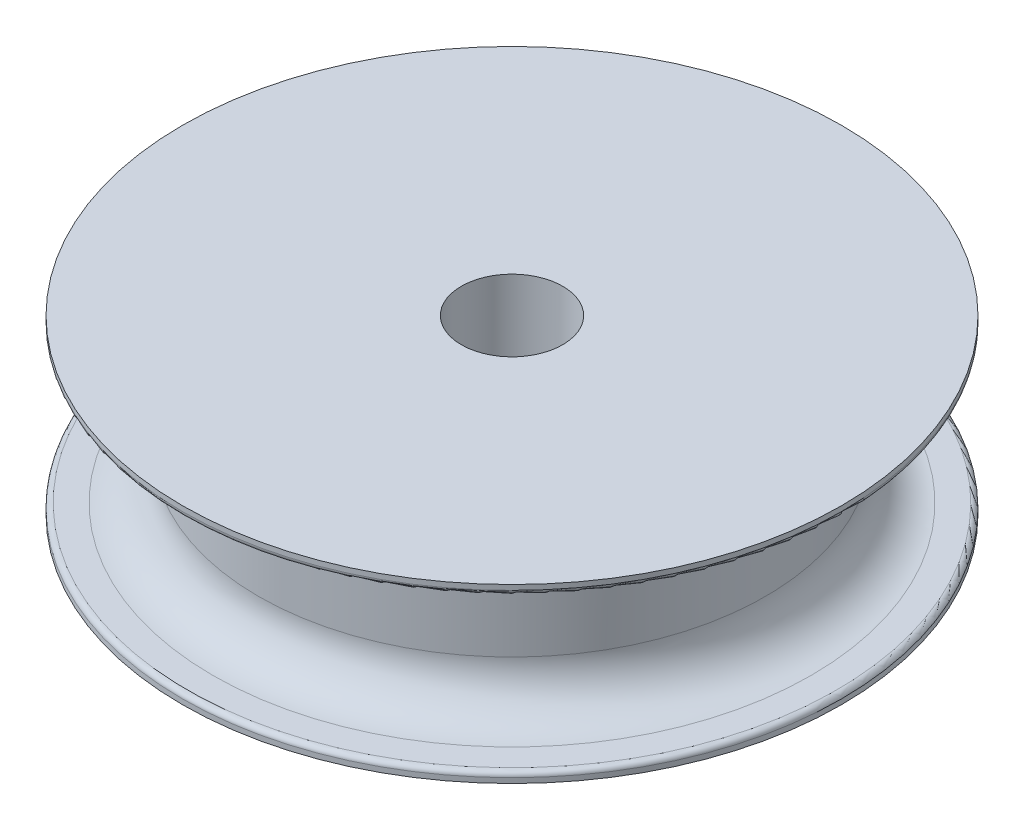
from build123d import *

# Parameters (mm, degrees)
BOSS_EXTRUDE1_DEPTH      = 15
BOSS_EXTRUDE1_DEPTH_BACK = 15
SKETCH1_R                = 50
SKETCH2_R                = 65
BOSS_EXTRUDE2_DEPTH      = 2
BOSS_EXTRUDE3_START      = 2
SKETCH3_R                = 65
BOSS_EXTRUDE3_DEPTH      = 2
FILLET1_R                = 9
FILLET2_R                = 1
FILLET3_R                = 1
FILLET4_R                = 9
CUT_EXTRUDE1_REACH       = 100.01
SKETCH4_R                = 10


with BuildPart() as part:
    # Sketch1 → Boss-Extrude1 (new, two sides: drawn at the far end of the back side and taken through both)
    with BuildSketch(Plane(origin=(0, 0, 0), x_dir=(1, 0, 0), z_dir=(0, 1, 0)).offset(-BOSS_EXTRUDE1_DEPTH_BACK)):
        Circle(SKETCH1_R)
    extrude(amount=BOSS_EXTRUDE1_DEPTH + BOSS_EXTRUDE1_DEPTH_BACK)

    # Sketch2 → Boss-Extrude2 (add)
    with BuildSketch(Plane.XZ.offset(15)):
        Circle(SKETCH2_R)
    extrude(amount=BOSS_EXTRUDE2_DEPTH)

    # Sketch3 → Boss-Extrude3 (add)
    with BuildSketch(Plane(origin=(0, 15, 0), x_dir=(1, 0, 0), z_dir=(0, 1, 0)).offset(BOSS_EXTRUDE3_START)):
        Circle(SKETCH3_R)
    extrude(amount=-BOSS_EXTRUDE3_DEPTH)

    # Fillet1
    fillet1_edges = [part.edges().sort_by_distance(p)[0] for p in [
        (-50, -15, 0),
    ]]
    fillet(fillet1_edges, radius=FILLET1_R)

    # Fillet2
    fillet2_edges = [part.edges().sort_by_distance(p)[0] for p in [
        (-65, -15, 0),
    ]]
    fillet(fillet2_edges, radius=FILLET2_R)

    # Fillet3
    fillet3_edges = [part.edges().sort_by_distance(p)[0] for p in [
        (-65, 15, 0),
    ]]
    fillet(fillet3_edges, radius=FILLET3_R)

    # Fillet4
    fillet4_edges = [part.edges().sort_by_distance(p)[0] for p in [
        (-50, 15, 0),
    ]]
    fillet(fillet4_edges, radius=FILLET4_R)

    # Sketch4 → Cut-Extrude1 (cut, up to next)
    with BuildSketch(Plane(origin=(0, 17, 0), x_dir=(1, 0, 0), z_dir=(0, 1, 0)), mode=Mode.PRIVATE) as cut_extrude1_sk1:
        Circle(SKETCH4_R)
    cut_extrude1_tool1 = extrude(cut_extrude1_sk1.sketch, amount=-CUT_EXTRUDE1_REACH, mode=Mode.PRIVATE) & part.part
    add(cut_extrude1_tool1.solids().sort_by_distance((0, 17, 0))[0], mode=Mode.SUBTRACT)


solid = part.part
